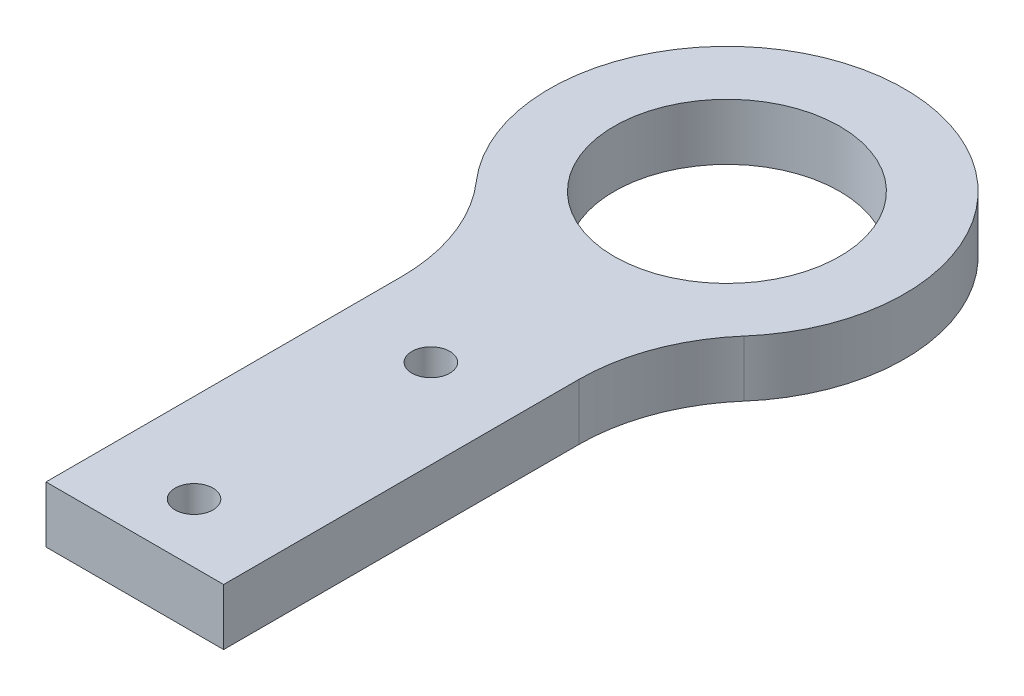
from build123d import *

# Parameters (mm, degrees)
SKETCH1_R           = 9.525
SKETCH1_R_2         = 1.6
BOSS_EXTRUDE2_DEPTH = 4.7625


with BuildPart() as part:
    # Sketch1 → Boss-Extrude2 (new body)
    with BuildSketch(Plane(origin=(0, 0, 0), x_dir=(1, 0, 0), z_dir=(0, 1, 0))):
        with BuildLine():
            Line((-7.5, 0), (7.5, 0))
            Line((7.5, 0), (7.5, 30))
            ThreePointArc((7.5, 30), (8.481591846, 35.413153058), (11.301369863, 40.136986301))
            ThreePointArc((11.301369863, 40.136986301), (0, 65), (-11.301369863, 40.136986301))
            ThreePointArc((-11.301369863, 40.136986301), (-8.481591846, 35.413153058), (-7.5, 30))
            Line((-7.5, 30), (-7.5, 0))
        make_face()
        with Locations((0, 50)):
            Circle(SKETCH1_R, mode=Mode.SUBTRACT)
        with Locations((0, 5)):
            Circle(SKETCH1_R_2, mode=Mode.SUBTRACT)
        with Locations((0, 25)):
            Circle(SKETCH1_R_2, mode=Mode.SUBTRACT)
    extrude(amount=BOSS_EXTRUDE2_DEPTH)


solid = part.part
